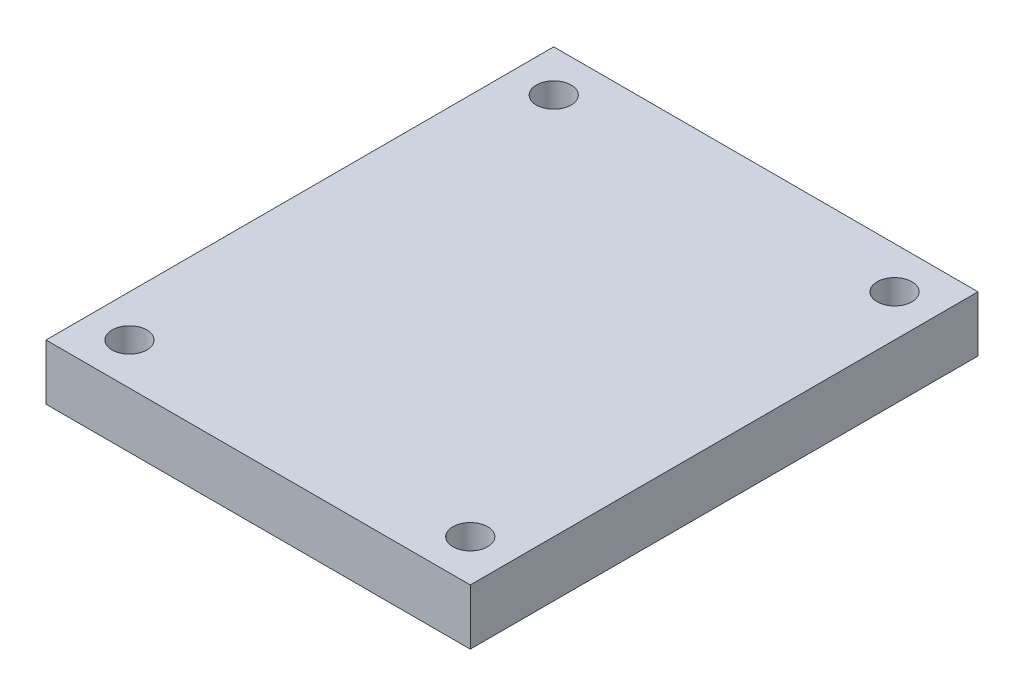
from build123d import *

# Parameters (mm, degrees)
SKETCH1_W             = 24.5
SKETCH1_H             = 24.5
BOSS_EXTRUDE1_DEPTH   = 2
SKETCH2_W             = 30.5
SKETCH2_H             = 36.5
SKETCH2_W_2           = 24.5
SKETCH2_H_2           = 24.5
BOSS_EXTRUDE2_DEPTH   = 4
M3X0_5_TAPPED_HOLE1_D = 2.5


with BuildPart() as part:
    # Sketch1 → Boss-Extrude1 (new body, symmetric)
    with BuildSketch(Plane(origin=(0, 0, 0), x_dir=(1, 0, 0), z_dir=(0, 1, 0))):
        Rectangle(SKETCH1_W, SKETCH1_H)
    extrude(amount=BOSS_EXTRUDE1_DEPTH, both=True)

    # Sketch2 → Boss-Extrude2 (add)
    with BuildSketch(Plane(origin=(0, 2, 0), x_dir=(1, 0, 0), z_dir=(0, 1, 0))):
        Rectangle(SKETCH2_W, SKETCH2_H)
        Rectangle(SKETCH2_W_2, SKETCH2_H_2, mode=Mode.SUBTRACT)
    extrude(amount=-BOSS_EXTRUDE2_DEPTH)

    # M3x0.5 Tapped Hole1 (through all)
    with Locations(Plane(origin=(0, 2, 0), x_dir=(1, 0, 0), z_dir=(0, 1, 0))):
        with Locations((-12.25, 15.25), (12.25, 15.25), (-12.25, -15.25), (12.25, -15.25)):
            Hole(M3X0_5_TAPPED_HOLE1_D / 2)


solid = part.part
